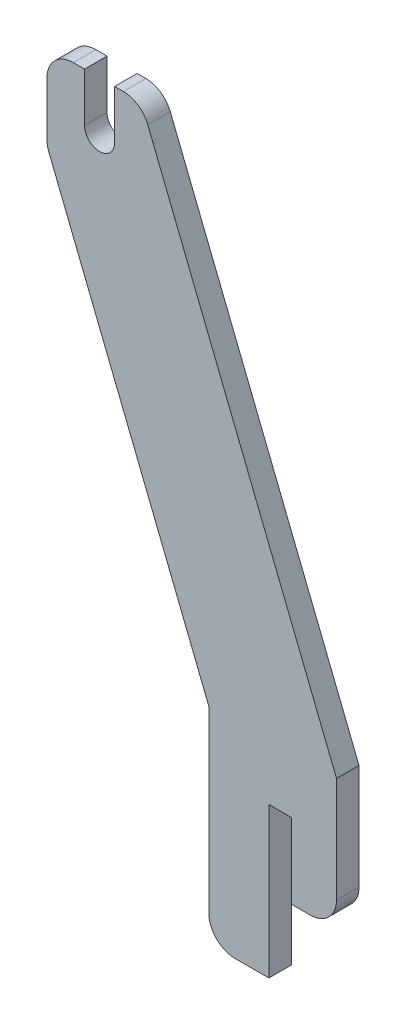
from build123d import *

# Parameters (mm, degrees)
RESSALTO_EXTRUS_O1_DEPTH = 6


with BuildPart() as part:
    # Model → Ressalto-extrusão1 (new body)
    with BuildSketch(Plane.XY):
        with BuildLine():
            Line((216.587601096, 108.090872109), (216.587601096, 136.090872109))
            Line((216.587601096, 136.090872109), (166.347707202, 261.690606843))
            ThreePointArc((166.347707202, 261.690606843), (163.772772031, 264.887342722), (159.848370366, 266.090872109))
            Line((159.848370366, 266.090872109), (157.518730442, 266.090872109))
            Line((157.518730442, 266.090872109), (157.518730442, 253.090872109))
            ThreePointArc((157.518730442, 253.090872109), (153.518730442, 249.090872109), (149.518730442, 253.090872109))
            Line((149.518730442, 253.090872109), (149.518730442, 266.090872109))
            Line((149.518730442, 266.090872109), (146.518730442, 266.090872109))
            ThreePointArc((146.518730442, 266.090872109), (141.568982974, 264.040619577), (139.518730442, 259.090872109))
            Line((139.518730442, 259.090872109), (139.518730442, 244.812476299))
            ThreePointArc((139.518730442, 244.812476299), (139.645035735, 243.488723651), (140.019393606, 242.212741564))
            Line((140.019393606, 242.212741564), (182.587601096, 135.792222839))
            Line((182.587601096, 135.792222839), (182.587601096, 88.090872109))
            ThreePointArc((182.587601096, 88.090872109), (184.637853628, 83.141124641), (189.587601096, 81.090872109))
            Line((189.587601096, 81.090872109), (198.587601096, 81.090872109))
            Line((198.587601096, 81.090872109), (198.587601096, 121.090872109))
            Line((198.587601096, 121.090872109), (204.587601096, 121.090872109))
            Line((204.587601096, 121.090872109), (204.587601096, 101.090872109))
            Line((204.587601096, 101.090872109), (209.587601096, 101.090872109))
            ThreePointArc((209.587601096, 101.090872109), (214.537348564, 103.141124641), (216.587601096, 108.090872109))
        make_face()
    extrude(amount=RESSALTO_EXTRUS_O1_DEPTH)


solid = part.part
